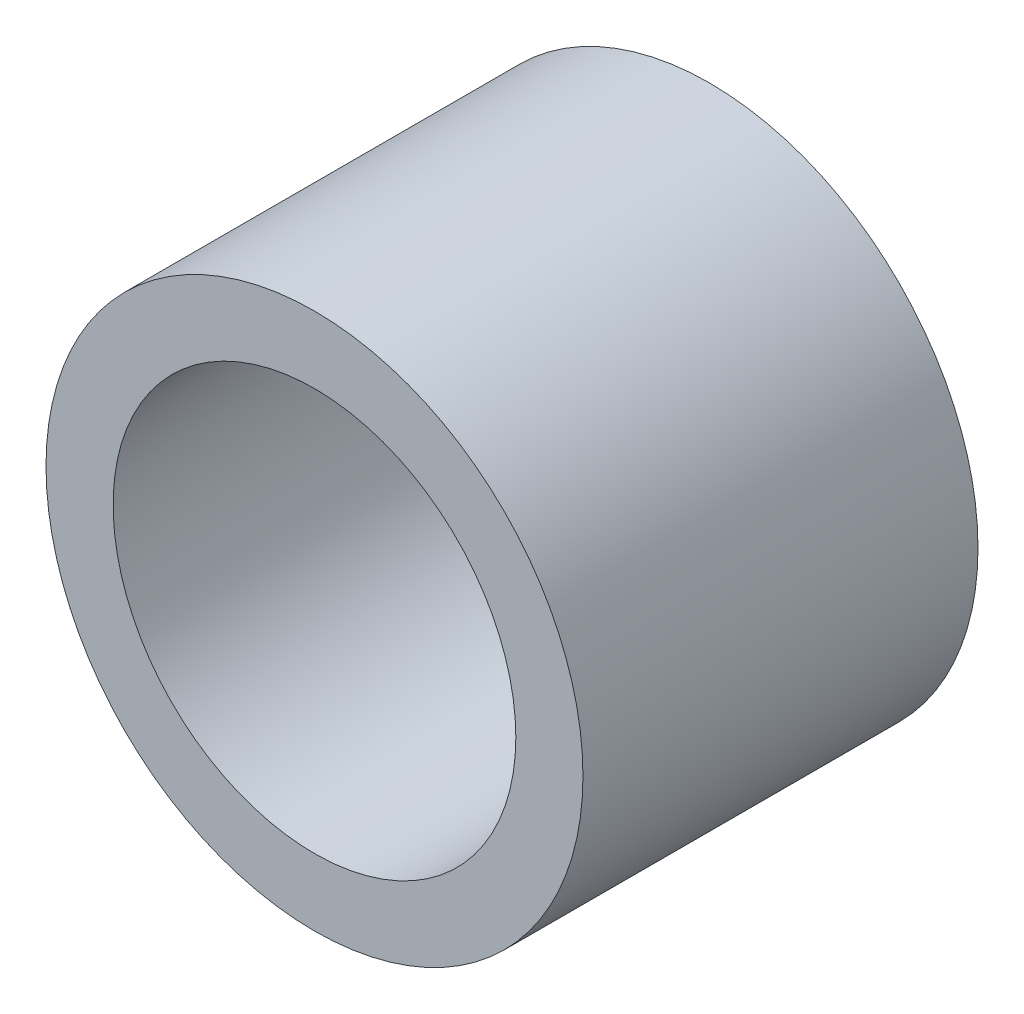
from build123d import *

# Parameters (mm, degrees)
SKETCH1_R           = 7
SKETCH1_R_2         = 5.25
BOSS_EXTRUDE1_DEPTH = 10.3


with BuildPart() as part:
    # Sketch1 → Boss-Extrude1 (new body)
    with BuildSketch(Plane.XY):
        Circle(SKETCH1_R)
        Circle(SKETCH1_R_2, mode=Mode.SUBTRACT)
    extrude(amount=BOSS_EXTRUDE1_DEPTH)


solid = part.part
